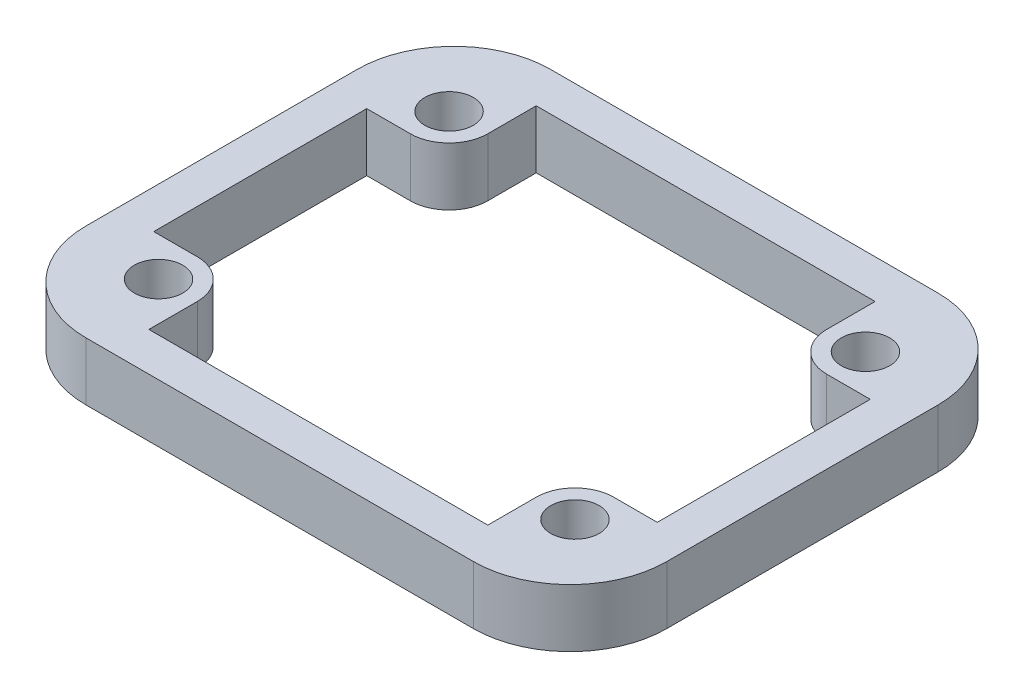
from build123d import *

# Parameters (mm, degrees)
SKETCH1_W           = 30
SKETCH1_H           = 24
BOSS_EXTRUDE1_DEPTH = 3
SKETCH2_R           = 1.25
CUT_EXTRUDE1_DEPTH  = 3
CUT_EXTRUDE2_DEPTH  = 3
FILLET1_R           = 5


with BuildPart() as part:
    # Sketch1 → Boss-Extrude1 (new body)
    with BuildSketch(Plane(origin=(0, 0, 0), x_dir=(1, 0, 0), z_dir=(0, 1, 0))):
        Rectangle(SKETCH1_W, SKETCH1_H)
    extrude(amount=BOSS_EXTRUDE1_DEPTH)

    # Sketch2 → Cut-Extrude1 (cut)
    with BuildSketch(Plane(origin=(0, 0, 0), x_dir=(1, 0, 0), z_dir=(0, 1, 0))):
        with Locations((-10.75, 7.5)):
            Circle(SKETCH2_R)
        with Locations((-10.75, -7.5)):
            Circle(SKETCH2_R)
        with Locations((10.75, -7.5)):
            Circle(SKETCH2_R)
        with Locations((10.75, 7.5)):
            Circle(SKETCH2_R)
    extrude(amount=CUT_EXTRUDE1_DEPTH, mode=Mode.SUBTRACT)

    # Sketch4 → Cut-Extrude2 (cut)
    with BuildSketch(Plane(origin=(0, 0, 0), x_dir=(1, 0, 0), z_dir=(0, 1, 0))):
        with BuildLine():
            Line((-10.75, 5.5), (-13, 5.5))
            Line((-13, 5.5), (-13, -5.5))
            Line((-13, -5.5), (-10.75, -5.5))
            ThreePointArc((-10.75, -5.5), (-9.335786438, -6.085786438), (-8.75, -7.5))
            Line((-8.75, -7.5), (-8.75, -10))
            Line((-8.75, -10), (8.75, -10))
            Line((8.75, -10), (8.75, -7.5))
            ThreePointArc((8.75, -7.5), (9.335786438, -6.085786438), (10.75, -5.5))
            Line((10.75, -5.5), (13, -5.5))
            Line((13, -5.5), (13, 5.5))
            Line((13, 5.5), (10.75, 5.5))
            ThreePointArc((10.75, 5.5), (9.335786438, 6.085786438), (8.75, 7.5))
            Line((8.75, 7.5), (8.75, 10))
            Line((8.75, 10), (-8.75, 10))
            Line((-8.75, 10), (-8.75, 7.5))
            ThreePointArc((-8.75, 7.5), (-9.335786438, 6.085786438), (-10.75, 5.5))
        make_face()
    extrude(amount=CUT_EXTRUDE2_DEPTH, mode=Mode.SUBTRACT)

    # Fillet1
    fillet1_edges = [part.edges().sort_by_distance(p)[0] for p in [
        (15, 1.5, 12),
        (-15, 1.5, 12),
        (-15, 1.5, -12),
        (15, 1.5, -12),
    ]]
    fillet(fillet1_edges, radius=FILLET1_R)


solid = part.part
